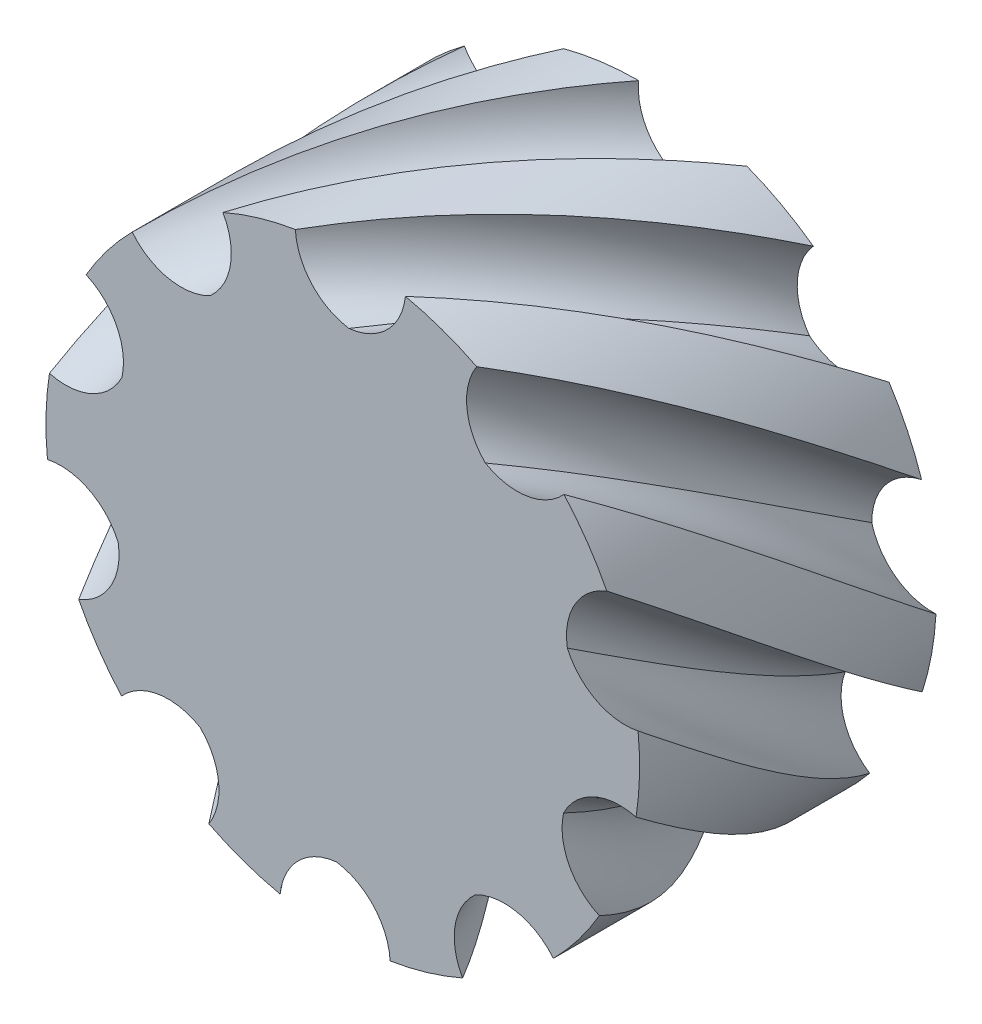
from build123d import *

# Parameters (mm, degrees)
SKETCH1_R         = 5
EXTRUDE1_DEPTH    = 5
CIRPATTERN1_COUNT = 10


with BuildPart() as part:
    # Sketch1 → Extrude1 (new body)
    with BuildSketch(Plane.XY):
        Circle(SKETCH1_R)
    extrude(amount=EXTRUDE1_DEPTH)

    # Cut-Sweep1: sweep along a curve in space
    with BuildLine() as cut_sweep1_path:
        add(Edge.make_bspline(
            [(-1.746e-14, 5, 5), (0.6961931500490736, 5.000000000000002, 4.113579350583758), (2.094951939643919, 4.703036521551189, 2.331852389649746), (3.825477778446608, 3.445735903848895, -0.3318523896497451), (4.540147066743169, 2.207204003828979, -2.1135793505837586), (4.755282581475767, 1.5450849718747413, -3)],
            knots=[0, 0, 0, 0, 0.3333333333333333, 0.6666666666666666, 1, 1, 1, 1], degree=3))
    with BuildLine() as cut_sweep1_axis:
        Line((0, 0, 5), (0, 0, -3))
    # Sketch2 → Cut-Sweep1 (sweep, cut)
    with BuildSketch(Plane.XY.offset(5)):
        with BuildLine():
            Line((1.0552569055351697, 4.88737484375), (1.5875, 6.35))
            Line((1.5875, 6.35), (-1.5875, 6.35))
            Line((-1.5875, 6.35), (-0.7980252766557553, 4.935904745618426))
            ThreePointArc((-0.7980252766557553, 4.935904745618426), (-0.5238292652560141, 4.279546174045879), (0.1032716893906448, 3.9437867068293446))
            ThreePointArc((0.1032716893906448, 3.9437867068293446), (0.7470855167579838, 4.2462660992429395), (1.0552569055351697, 4.88737484375))
        make_face()
    cut_sweep1 = sweep(path=cut_sweep1_path.line, binormal=cut_sweep1_axis.edges()[0], mode=Mode.SUBTRACT)

    # CirPattern1: Cut-Sweep1 ×10 about axis
    cirpattern1_axis = Axis((0, 0, 0), (0, 0, -1))
    for i in range(1, CIRPATTERN1_COUNT):
        add(cut_sweep1.rotate(cirpattern1_axis, i * 360 / CIRPATTERN1_COUNT), mode=Mode.SUBTRACT)


solid = part.part
